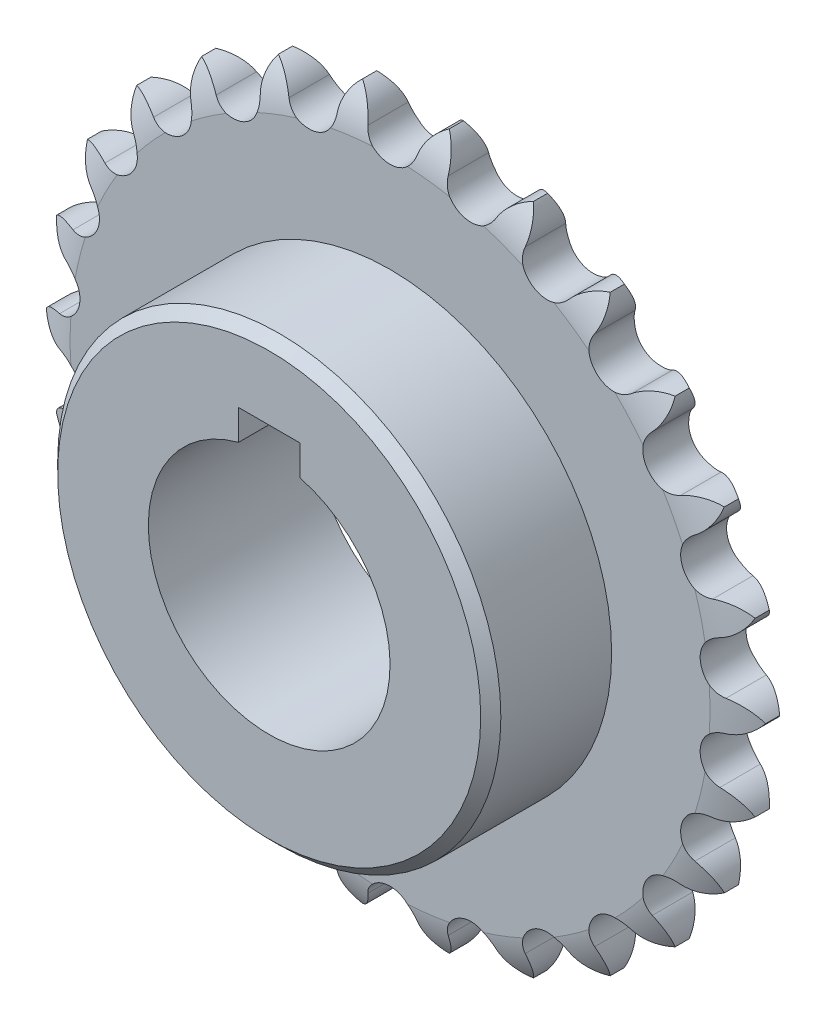
from build123d import *

# Parameters (mm, degrees)
SKETCH1_R           = 19.05
BOSS_EXTRUDE1_DEPTH = 3.6155
SKETCH2_W           = 19.05
SKETCH2_H           = 15.875
SKETCH3_W           = 9.65
SKETCH3_H           = 4.76
CUT_EXTRUDE1_DEPTH  = 27.281
CHAMFER2_SIZE       = 1.5875
SCALE_1_SCALE       = 0.5
SCALE_2_SCALE       = 2


with BuildPart() as part:
    # Sketch1 → Boss-Extrude1 (new body, symmetric)
    with BuildSketch(Plane.XY):
        with BuildLine():
            ThreePointArc((6.832203091, 56.268254805), (4.963717297, 54.655608899), (3.929721647, 52.414466562))
            ThreePointArc((3.929721647, 52.414466562), (0, 49.2633), (-3.929721647, 52.414466562))
            ThreePointArc((-3.929721647, 52.414466562), (-4.963717297, 54.655608899), (-6.832203091, 56.268254805))
            ThreePointArc((-6.832203091, 56.268254805), (-8.260462658, 54.25531154), (-8.728071806, 51.831841369))
            ThreePointArc((-8.728071806, 51.831841369), (-11.789479364, 47.831798034), (-16.359133961, 49.950953477))
            ThreePointArc((-16.359133961, 49.950953477), (-17.899424044, 51.879520935), (-20.099546463, 52.998148363))
            ThreePointArc((-20.099546463, 52.998148363), (-21.004574548, 50.701892683), (-20.87862145, 48.236937958))
            ThreePointArc((-20.87862145, 48.236937958), (-22.893797041, 43.620485829), (-27.837812873, 44.58447254))
            ThreePointArc((-27.837812873, 44.58447254), (-29.794881328, 46.088383789), (-32.198777254, 46.647982178))
            ThreePointArc((-32.198777254, 46.647982178), (-32.527976914, 44.201864118), (-31.815781507, 41.838679046))
            ThreePointArc((-31.815781507, 41.838679046), (-32.66761045, 36.87410954), (-37.698659287, 36.626904117))
            ThreePointArc((-37.698659287, 36.626904117), (-39.958768409, 37.618757301), (-42.426732148, 37.586804827))
            ThreePointArc((-42.426732148, 37.586804827), (-42.160971496, 35.132983877), (-40.903923988, 33.008908185))
            ThreePointArc((-40.903923988, 33.008908185), (-40.542901081, 27.984744038), (-45.368596652, 26.54071316))
            ThreePointArc((-45.368596652, 26.54071316), (-47.800397114, 26.962865377), (-50.188999585, 26.341219003))
            ThreePointArc((-50.188999585, 26.341219003), (-49.343723664, 24.022302317), (-47.614879086, 22.260779564))
            ThreePointArc((-47.614879086, 22.260779564), (-46.061985668, 17.469006932), (-50.401876088, 14.912072425))
            ThreePointArc((-50.401876088, 14.912072425), (-52.864040486, 14.739989724), (-55.034464796, 13.564777276))
            ThreePointArc((-55.034464796, 13.564777276), (-53.658797969, 11.515531863), (-51.558630485, 10.218935348))
            ThreePointArc((-51.558630485, 10.218935348), (-48.904115077, 5.93803464), (-52.505981689, 2.416796245))
            ThreePointArc((-52.505981689, 2.416796245), (-54.855417978, 1.660479445), (-56.681526955, 0))
            ThreePointArc((-56.681526955, 0), (-54.855417978, -1.660479445), (-52.505981689, -2.416796245))
            ThreePointArc((-52.505981689, -2.416796245), (-48.904115077, -5.93803464), (-51.558630485, -10.218935348))
            ThreePointArc((-51.558630485, -10.218935348), (-53.658797969, -11.515531863), (-55.034464796, -13.564777276))
            ThreePointArc((-55.034464796, -13.564777276), (-52.864040486, -14.739989724), (-50.401876088, -14.912072425))
            ThreePointArc((-50.401876088, -14.912072425), (-46.061985668, -17.469006932), (-47.614879086, -22.260779564))
            ThreePointArc((-47.614879086, -22.260779564), (-49.343723664, -24.022302317), (-50.188999585, -26.341219003))
            ThreePointArc((-50.188999585, -26.341219003), (-47.800397114, -26.962865377), (-45.368596652, -26.54071316))
            ThreePointArc((-45.368596652, -26.54071316), (-40.542901081, -27.984744038), (-40.903923988, -33.008908185))
            ThreePointArc((-40.903923988, -33.008908185), (-42.160971496, -35.132983877), (-42.426732148, -37.586804827))
            ThreePointArc((-42.426732148, -37.586804827), (-39.958768409, -37.618757301), (-37.698659287, -36.626904117))
            ThreePointArc((-37.698659287, -36.626904117), (-32.66761045, -36.87410954), (-31.815781507, -41.838679046))
            ThreePointArc((-31.815781507, -41.838679046), (-32.527976914, -44.201864118), (-32.198777254, -46.647982178))
            ThreePointArc((-32.198777254, -46.647982178), (-29.794881328, -46.088383789), (-27.837812873, -44.58447254))
            ThreePointArc((-27.837812873, -44.58447254), (-22.893797041, -43.620485829), (-20.87862145, -48.236937958))
            ThreePointArc((-20.87862145, -48.236937958), (-21.004574548, -50.701892683), (-20.099546463, -52.998148363))
            ThreePointArc((-20.099546463, -52.998148363), (-17.899424044, -51.879520935), (-16.359133961, -49.950953477))
            ThreePointArc((-16.359133961, -49.950953477), (-11.789479364, -47.831798034), (-8.728071806, -51.831841369))
            ThreePointArc((-8.728071806, -51.831841369), (-8.260462658, -54.25531154), (-6.832203091, -56.268254805))
            ThreePointArc((-6.832203091, -56.268254805), (-4.963717297, -54.655608899), (-3.929721647, -52.414466562))
            ThreePointArc((-3.929721647, -52.414466562), (0, -49.2633), (3.929721647, -52.414466562))
            ThreePointArc((3.929721647, -52.414466562), (4.963717297, -54.655608899), (6.832203091, -56.268254805))
            ThreePointArc((6.832203091, -56.268254805), (8.260462658, -54.25531154), (8.728071806, -51.831841369))
            ThreePointArc((8.728071806, -51.831841369), (11.789479365, -47.831798034), (16.359133961, -49.950953477))
            ThreePointArc((16.359133961, -49.950953477), (17.899424044, -51.879520935), (20.099546463, -52.998148363))
            ThreePointArc((20.099546463, -52.998148363), (21.004574548, -50.701892683), (20.87862145, -48.236937958))
            ThreePointArc((20.87862145, -48.236937958), (22.893797041, -43.620485829), (27.837812873, -44.58447254))
            ThreePointArc((27.837812873, -44.58447254), (29.794881328, -46.088383789), (32.198777254, -46.647982178))
            ThreePointArc((32.198777254, -46.647982178), (32.527976914, -44.201864118), (31.815781507, -41.838679046))
            ThreePointArc((31.815781507, -41.838679046), (32.66761045, -36.87410954), (37.698659287, -36.626904117))
            ThreePointArc((37.698659287, -36.626904117), (39.958768409, -37.618757301), (42.426732148, -37.586804827))
            ThreePointArc((42.426732148, -37.586804827), (42.160971496, -35.132983877), (40.903923988, -33.008908185))
            ThreePointArc((40.903923988, -33.008908185), (40.542901081, -27.984744038), (45.368596652, -26.54071316))
            ThreePointArc((45.368596652, -26.54071316), (47.800397114, -26.962865377), (50.188999585, -26.341219003))
            ThreePointArc((50.188999585, -26.341219003), (49.343723664, -24.022302317), (47.614879086, -22.260779564))
            ThreePointArc((47.614879086, -22.260779564), (46.061985668, -17.469006932), (50.401876088, -14.912072425))
            ThreePointArc((50.401876088, -14.912072425), (52.864040486, -14.739989724), (55.034464796, -13.564777276))
            ThreePointArc((55.034464796, -13.564777276), (53.658797969, -11.515531863), (51.558630485, -10.218935348))
            ThreePointArc((51.558630485, -10.218935348), (48.904115077, -5.93803464), (52.505981689, -2.416796245))
            ThreePointArc((52.505981689, -2.416796245), (54.855417978, -1.660479445), (56.681526955, 0))
            ThreePointArc((56.681526955, 0), (54.855417978, 1.660479445), (52.505981689, 2.416796245))
            ThreePointArc((52.505981689, 2.416796245), (48.904115077, 5.93803464), (51.558630485, 10.218935348))
            ThreePointArc((51.558630485, 10.218935348), (53.658797969, 11.515531863), (55.034464796, 13.564777276))
            ThreePointArc((55.034464796, 13.564777276), (52.864040486, 14.739989724), (50.401876088, 14.912072425))
            ThreePointArc((50.401876088, 14.912072425), (46.061985668, 17.469006932), (47.614879086, 22.260779564))
            ThreePointArc((47.614879086, 22.260779564), (49.343723664, 24.022302317), (50.188999585, 26.341219003))
            ThreePointArc((50.188999585, 26.341219003), (47.800397114, 26.962865377), (45.368596652, 26.54071316))
            ThreePointArc((45.368596652, 26.54071316), (40.542901081, 27.984744038), (40.903923988, 33.008908185))
            ThreePointArc((40.903923988, 33.008908185), (42.160971496, 35.132983877), (42.426732148, 37.586804827))
            ThreePointArc((42.426732148, 37.586804827), (39.958768409, 37.618757301), (37.698659287, 36.626904117))
            ThreePointArc((37.698659287, 36.626904117), (32.66761045, 36.87410954), (31.815781507, 41.838679046))
            ThreePointArc((31.815781507, 41.838679046), (32.527976914, 44.201864118), (32.198777254, 46.647982178))
            ThreePointArc((32.198777254, 46.647982178), (29.794881328, 46.088383789), (27.837812873, 44.58447254))
            ThreePointArc((27.837812873, 44.58447254), (22.893797041, 43.620485829), (20.87862145, 48.236937958))
            ThreePointArc((20.87862145, 48.236937958), (21.004574548, 50.701892683), (20.099546463, 52.998148363))
            ThreePointArc((20.099546463, 52.998148363), (17.899424044, 51.879520935), (16.359133961, 49.950953477))
            ThreePointArc((16.359133961, 49.950953477), (11.789479364, 47.831798034), (8.728071806, 51.831841369))
            ThreePointArc((8.728071806, 51.831841369), (8.260462658, 54.25531154), (6.832203091, 56.268254805))
        make_face()
        Circle(SKETCH1_R, mode=Mode.SUBTRACT)
    extrude(amount=BOSS_EXTRUDE1_DEPTH, both=True)

    # Sketch2 → Revolve1 (revolve)
    with BuildSketch(Plane(origin=(0, 0, 0), x_dir=(0, 0, -1), z_dir=(1, 0, 0))):
        with Locations((-13.1405, 26.9875)):
            Rectangle(SKETCH2_W, SKETCH2_H)
    revolve(axis=Axis((0, 0, 0), (0, 0, 1)))

    # Sketch3 → Cut-Extrude1 (cut, through all)
    with BuildSketch(Plane.XY.offset(22.6655)):
        with Locations((0, 20.808832709)):
            Rectangle(SKETCH3_W, SKETCH3_H)
    extrude(amount=-CUT_EXTRUDE1_DEPTH, mode=Mode.SUBTRACT)

    # Sketch4 → Cut-Revolve1 (revolve, cut)
    with BuildSketch(Plane(origin=(0, 0, 0), x_dir=(0, 0, -1), z_dir=(1, 0, 0))):
        with BuildLine():
            Line((-3.6155, 50.42), (-12.330867659, 50.42))
            Line((-12.330867659, 50.42), (-12.330867659, 56.89))
            Line((-12.330867659, 56.89), (-0.954045736, 56.89))
            ThreePointArc((-0.954045736, 56.89), (-2.739073023, 53.841877757), (-3.6155, 50.42))
        make_face()
    cut_revolve1 = revolve(axis=Axis((0, 0, 0), (0, 0, 1)), mode=Mode.SUBTRACT)

    # Mirror1: Cut-Revolve1 across plane
    add(cut_revolve1.mirror(Plane.XY), mode=Mode.SUBTRACT)

    # Chamfer2
    chamfer2_edges = [part.edges().sort_by_distance(p)[0] for p in [
        (0, -34.925, 22.6655),
    ]]
    chamfer(chamfer2_edges, length=CHAMFER2_SIZE)


with BuildPart() as part_1:
    # Scale 1: scaled about (-9e-09, -0.225936899, 6.41471309)
    add(part.part.scale(SCALE_1_SCALE).moved(Location((-4e-09, -0.112968449, 3.207356545))))


with BuildPart() as part_2:
    # Scale 2: scaled about (-9e-09, -0.225936899, 6.41471309)
    add(part_1.part.scale(SCALE_2_SCALE).moved(Location((9e-09, 0.225936899, -6.41471309))))


solid = part_2.part
